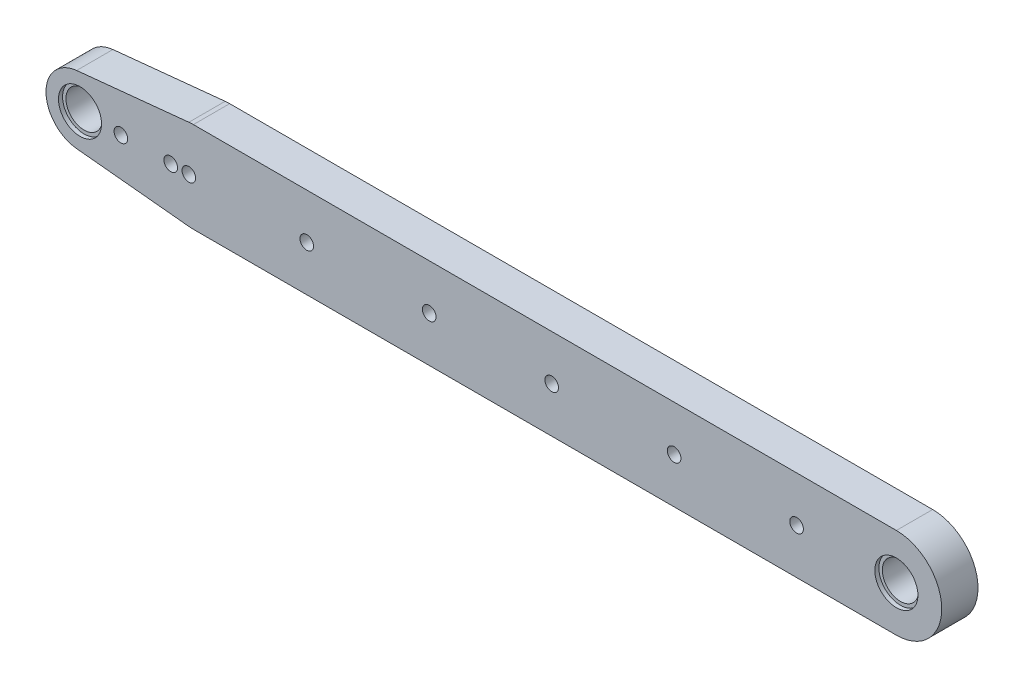
from build123d import *

# Parameters (mm, degrees)
EXTRUDE_1_DEPTH              = 8
HOLE_WIZARD_M3_2_D           = 3
HOLE_WIZARD_M5_1_D           = 8
HOLE_WIZARD_M5_1_CBORE_D     = 9.5
HOLE_WIZARD_M5_1_CBORE_DEPTH = 0.9
SKETCH_11_R                  = 1.5
CUT_EXTRUDE_1_DEPTH          = 1
CUT_EXTRUDE_1_DEPTH_BACK     = 9


with BuildPart() as part:
    # 草图1 → 凸台-拉伸1 (new body)
    with BuildSketch(Plane.XY):
        with BuildLine():
            Line((77.5, 10), (-77.5, 10))
            ThreePointArc((-77.5, 10), (-70.428932188, 7.071067812), (-67.5, 0))
            ThreePointArc((-67.5, 0), (-70.428932188, -7.071067812), (-77.5, -10))
            Line((-77.5, -10), (77.5, -10))
            ThreePointArc((77.5, -10), (87.5, 0), (77.5, 10))
        make_face()
        with BuildLine():
            ThreePointArc((-67.5, 0), (-70.428932188, 7.071067812), (-77.5, 10))
            ThreePointArc((-77.5, 10), (-78.000627751, 9.987460731), (-78.5, 9.949874371))
            ThreePointArc((-78.5, 9.949874371), (-87.5, 0), (-78.5, -9.949874371))
            ThreePointArc((-78.5, -9.949874371), (-78.000627751, -9.987460731), (-77.5, -10))
            ThreePointArc((-77.5, -10), (-70.428932188, -7.071067812), (-67.5, 0))
        make_face()
        with BuildLine():
            ThreePointArc((-78.5, -9.949874371), (-87.5, 0), (-78.5, 9.949874371))
            Line((-78.5, 9.949874371), (-103.25, 7.462405778))
            ThreePointArc((-103.25, 7.462405778), (-110, 0), (-103.25, -7.462405778))
            Line((-103.25, -7.462405778), (-78.5, -9.949874371))
        make_face()
    extrude(amount=EXTRUDE_1_DEPTH)

    # M3 螺纹孔2 (through all)
    with Locations(Plane.XY.offset(8)):
        with Locations((-78.5, 0), (-93.5, 0), (-82.5, 0)):
            Hole(HOLE_WIZARD_M3_2_D / 2)

    # M5 六角头螺栓的柱形沉头孔1 (through all)
    with Locations(Plane.XY.offset(8)):
        with Locations((-102.5, 0), (77.5, 0)):
            CounterBoreHole(HOLE_WIZARD_M5_1_D / 2, HOLE_WIZARD_M5_1_CBORE_D / 2, HOLE_WIZARD_M5_1_CBORE_DEPTH)

    # 草图11 → 切除-拉伸1 (cut, two sides)
    with BuildSketch(Plane.XY.offset(8)) as cut_extrude_1_sk:
        with Locations((-52.5, 0)):
            Circle(SKETCH_11_R)
        with Locations((-25.5, 0)):
            Circle(SKETCH_11_R)
        with Locations((1.5, 0)):
            Circle(SKETCH_11_R)
        with Locations((28.5, 0)):
            Circle(SKETCH_11_R)
        with Locations((55.5, 0)):
            Circle(SKETCH_11_R)
    extrude(amount=CUT_EXTRUDE_1_DEPTH, mode=Mode.SUBTRACT)
    extrude(cut_extrude_1_sk.sketch, amount=-CUT_EXTRUDE_1_DEPTH_BACK, mode=Mode.SUBTRACT)


solid = part.part
